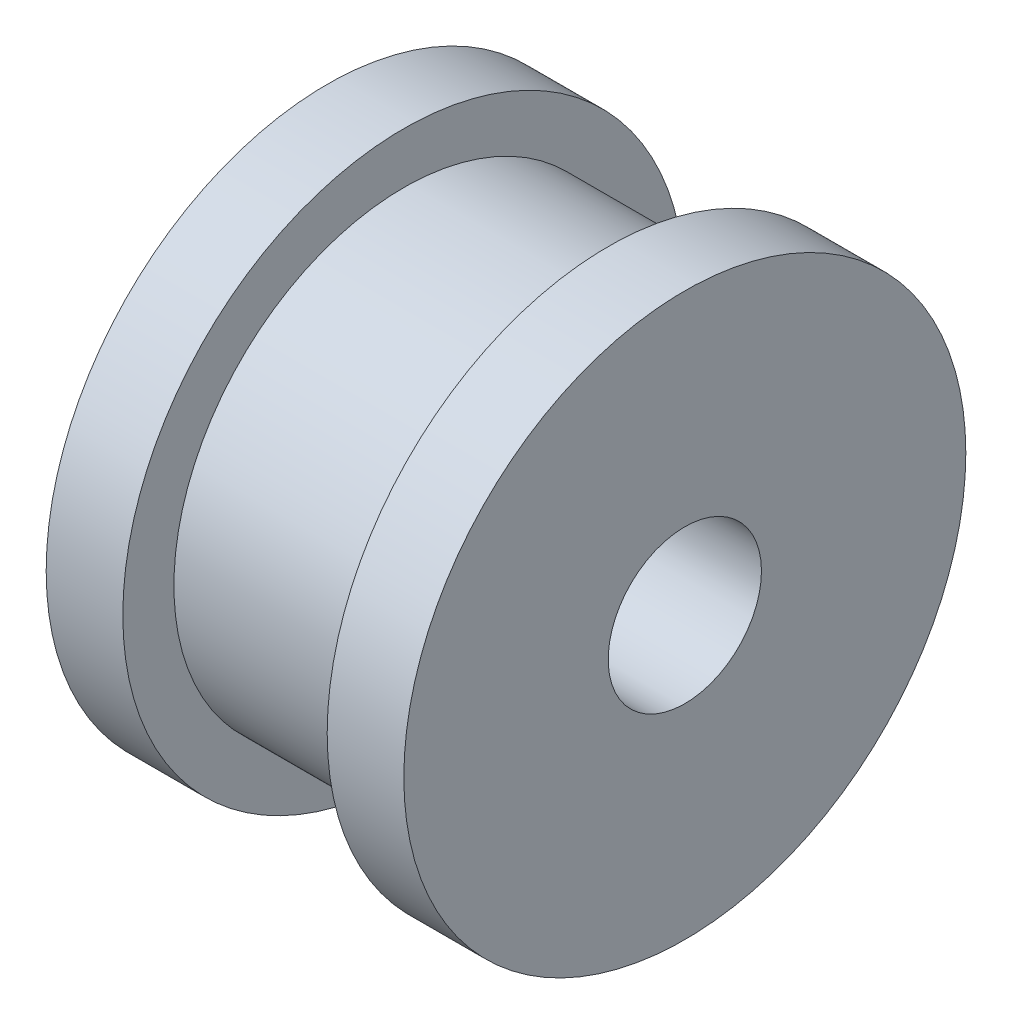
from build123d import *

# Parameters (mm, degrees)
SKETCH1_R               = 9
BOSS_EXTRUDE1_DEPTH     = 8
SKETCH3_R               = 11
BOSS_EXTRUDE2_DEPTH     = 3
SKETCH4_R               = 11
BOSS_EXTRUDE3_DEPTH     = 3
SKETCH2_R               = 3
CUT_EXTRUDE1_DEPTH      = 3
CUT_EXTRUDE1_DEPTH_BACK = 11


with BuildPart() as part:
    # Sketch1 → Boss-Extrude1 (new body)
    with BuildSketch(Plane(origin=(0, 0, 0), x_dir=(0, 0, -1), z_dir=(1, 0, 0))):
        Circle(SKETCH1_R)
    extrude(amount=BOSS_EXTRUDE1_DEPTH)

    # Sketch3 → Boss-Extrude2 (add)
    with BuildSketch(Plane(origin=(8, 0, 0), x_dir=(0, 0, -1), z_dir=(1, 0, 0))):
        Circle(SKETCH3_R)
    extrude(amount=BOSS_EXTRUDE2_DEPTH)

    # Sketch4 → Boss-Extrude3 (add)
    with BuildSketch(Plane.ZY):
        Circle(SKETCH4_R)
    extrude(amount=BOSS_EXTRUDE3_DEPTH)

    # Sketch2 → Cut-Extrude1 (cut, two sides)
    with BuildSketch(Plane(origin=(8, 0, 0), x_dir=(0, 0, -1), z_dir=(1, 0, 0))) as cut_extrude1_sk:
        Circle(SKETCH2_R)
    extrude(amount=CUT_EXTRUDE1_DEPTH, mode=Mode.SUBTRACT)
    extrude(cut_extrude1_sk.sketch, amount=-CUT_EXTRUDE1_DEPTH_BACK, mode=Mode.SUBTRACT)


solid = part.part
